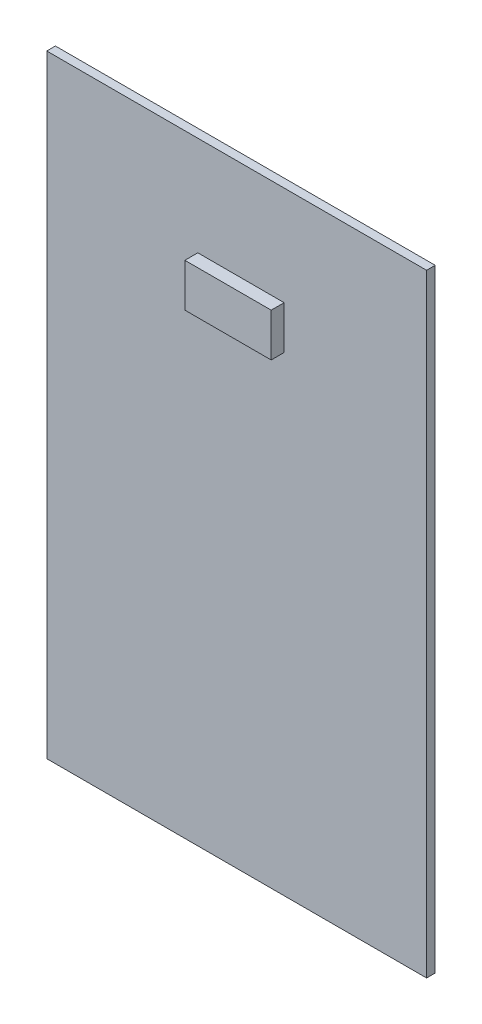
from build123d import *

# Parameters (mm, degrees)
SKETCH1_W           = 88
SKETCH1_H           = 142
BOSS_EXTRUDE1_DEPTH = 2
SKETCH2_W           = 20
SKETCH2_H           = 10
BOSS_EXTRUDE2_DEPTH = 3


with BuildPart() as part:
    # Sketch1 → Boss-Extrude1 (new body)
    with BuildSketch(Plane.XY):
        Rectangle(SKETCH1_W, SKETCH1_H)
    extrude(amount=BOSS_EXTRUDE1_DEPTH)

    # Sketch2 → Boss-Extrude2 (add)
    with BuildSketch(Plane.XY.offset(2)):
        with Locations((0.995282848, 43)):
            Rectangle(SKETCH2_W, SKETCH2_H)
    extrude(amount=BOSS_EXTRUDE2_DEPTH)


solid = part.part
